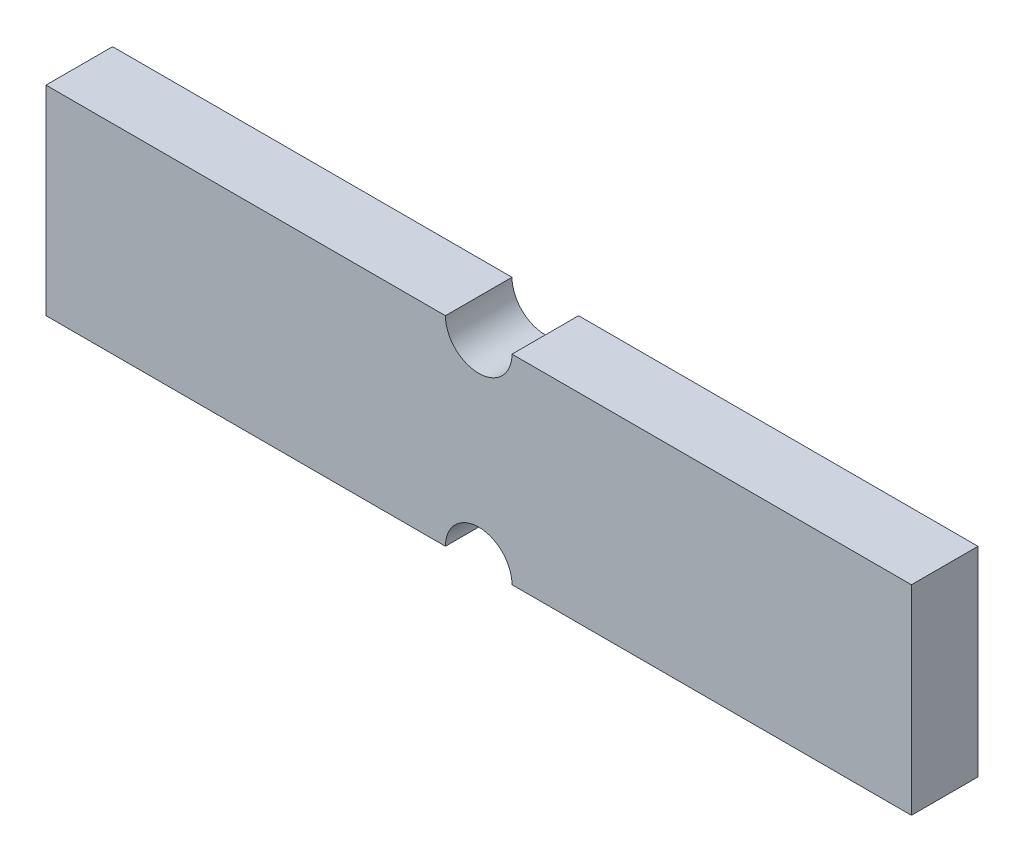
from build123d import *

# Parameters (mm, degrees)
EXTRUDE1_DEPTH = 12.7


with BuildPart() as part:
    # Sketch1 → Extrude1 (new body)
    with BuildSketch(Plane.XY):
        with BuildLine():
            Line((0, 0), (76.2, 0))
            ThreePointArc((76.2, 0), (82.55, 6.35), (88.9, 0))
            Line((88.9, 0), (165.1, 0))
            Line((165.1, 0), (165.1, 38.1))
            Line((165.1, 38.1), (88.9, 38.1))
            ThreePointArc((88.9, 38.1), (82.55, 31.75), (76.2, 38.1))
            Line((76.2, 38.1), (0, 38.1))
            Line((0, 38.1), (0, 0))
        make_face()
    extrude(amount=EXTRUDE1_DEPTH)


solid = part.part
